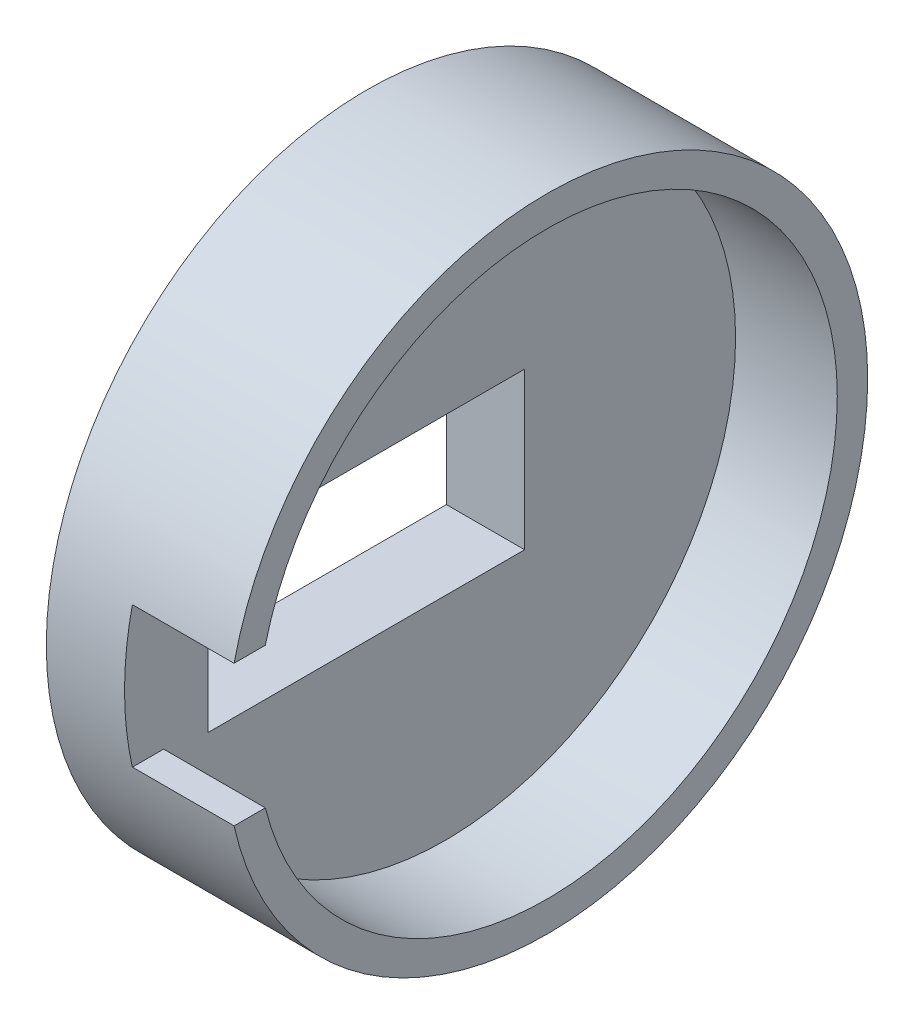
from build123d import *

# Parameters (mm, degrees)
CROQUIS1_R              = 41
CROQUIS1_R_2            = 37.1125
SALIENTE_EXTRUIR1_DEPTH = 10
CROQUIS2_R              = 41
SALIENTE_EXTRUIR2_DEPTH = 10
CROQUIS3_R              = 29.25
CROQUIS3_R_2            = 23.25
CORTAR_EXTRUIR3_DEPTH   = 5
CROQUIS6_R              = 41
SALIENTE_EXTRUIR4_DEPTH = 5
CROQUIS8_R              = 41
CROQUIS8_R_2            = 34.6125
SALIENTE_EXTRUIR9_DEPTH = 2
CROQUIS10_W             = 40.5
CROQUIS10_H             = 20
CORTAR_EXTRUIR5_DEPTH   = 25
CROQUIS11_R             = 41
CROQUIS11_R_2           = 34.6125
CORTAR_EXTRUIR7_DEPTH   = 2
CROQUIS16_R             = 37.1125
CROQUIS16_R_2           = 29.25
CROQUIS16_R_3           = 23.25
CROQUIS16_R_4           = 0.131738941
CORTAR_EXTRUIR8_DEPTH   = 5
CORTAR_EXTRUIR11_DEPTH  = 13


with BuildPart() as part:
    # Croquis1 → Saliente-Extruir1 (new body)
    with BuildSketch(Plane(origin=(0, 0, 0), x_dir=(0, 0, -1), z_dir=(1, 0, 0))):
        Circle(CROQUIS1_R)
        Circle(CROQUIS1_R_2, mode=Mode.SUBTRACT)
    extrude(amount=SALIENTE_EXTRUIR1_DEPTH)

    # Croquis2 → Saliente-Extruir2 (add)
    with BuildSketch(Plane.ZY):
        Circle(CROQUIS2_R)
    extrude(amount=SALIENTE_EXTRUIR2_DEPTH)

    # Croquis3 → Cortar-Extruir3 (cut)
    with BuildSketch(Plane(origin=(0, 0, 0), x_dir=(0, 0, -1), z_dir=(1, 0, 0))):
        Circle(CROQUIS3_R)
        Circle(CROQUIS3_R_2, mode=Mode.SUBTRACT)
    extrude(amount=-CORTAR_EXTRUIR3_DEPTH, mode=Mode.SUBTRACT)

    # Croquis6 → Saliente-Extruir4 (add)
    with BuildSketch(Plane.ZY.offset(10)):
        Circle(CROQUIS6_R)
    extrude(amount=SALIENTE_EXTRUIR4_DEPTH)

    # Croquis8 → Saliente-Extruir9 (add)
    with BuildSketch(Plane(origin=(10, 0, 0), x_dir=(0, 0, -1), z_dir=(1, 0, 0))):
        Circle(CROQUIS8_R)
        Circle(CROQUIS8_R_2, mode=Mode.SUBTRACT)
    extrude(amount=-SALIENTE_EXTRUIR9_DEPTH)

    # Croquis10 → Cortar-Extruir5 (cut)
    with BuildSketch(Plane.ZY.offset(15)):
        with Locations((10.108898944, 0)):
            Rectangle(CROQUIS10_W, CROQUIS10_H)
    extrude(amount=-CORTAR_EXTRUIR5_DEPTH, mode=Mode.SUBTRACT)

    # Croquis11 → Cortar-Extruir7 (cut)
    with BuildSketch(Plane(origin=(10, 0, 0), x_dir=(0, 0, -1), z_dir=(1, 0, 0))):
        Circle(CROQUIS11_R)
        Circle(CROQUIS11_R_2, mode=Mode.SUBTRACT)
    extrude(amount=-CORTAR_EXTRUIR7_DEPTH, mode=Mode.SUBTRACT)

    # Croquis16 → Cortar-Extruir8 (cut)
    with BuildSketch(Plane(origin=(0, 0, 0), x_dir=(0, 0, -1), z_dir=(1, 0, 0))):
        Circle(CROQUIS16_R)
        Circle(CROQUIS16_R_2, mode=Mode.SUBTRACT)
        Circle(CROQUIS16_R_3)
        with Locations((-25.248825272, -14.504135598)):
            Circle(CROQUIS16_R_4)
    extrude(amount=-CORTAR_EXTRUIR8_DEPTH, mode=Mode.SUBTRACT)

    # Croquis17 → Cortar-Extruir11 (cut)
    with BuildSketch(Plane(origin=(8, 0, 0), x_dir=(0, 0, -1), z_dir=(1, 0, 0))):
        with BuildLine():
            Line((-52.12049427, 3.696100056), (-40.002976192, -8.986762253))
            ThreePointArc((-40.002976192, -8.986762253), (-40.999999439, 0.006784093), (-40, 9))
            Line((-40, 9), (-52.12049427, 3.696100056))
        make_face()
        with BuildLine():
            ThreePointArc((-36.004689365, 9), (-37.1125, 0), (-36.004689365, -9))
            Line((-36.004689365, -9), (-30.358898944, -9))
            Line((-30.358898944, -9), (-30.358898944, 9))
            Line((-30.358898944, 9), (-36.004689365, 9))
        make_face()
        with BuildLine():
            Line((-30.358898944, -9), (-36.004689365, -9))
            ThreePointArc((-36.004689365, -9), (4.533961965, -36.834506175), (37.1125, 0))
            ThreePointArc((37.1125, 0), (4.533961965, 36.834506175), (-36.004689365, 9))
            Line((-36.004689365, 9), (-30.358898944, 9))
            Line((-30.358898944, 9), (-30.358898944, -9))
        make_face()
        with BuildLine():
            Line((-40.002976192, -8.986762253), (-39.990328523, -9))
            Line((-39.990328523, -9), (-36.004689365, -9))
            ThreePointArc((-36.004689365, -9), (-37.1125, 0), (-36.004689365, 9))
            Line((-36.004689365, 9), (-40, 9))
            ThreePointArc((-40, 9), (-40.999999439, 0.006784093), (-40.002976192, -8.986762253))
        make_face()
    extrude(amount=-CORTAR_EXTRUIR11_DEPTH, mode=Mode.SUBTRACT)


solid = part.part
